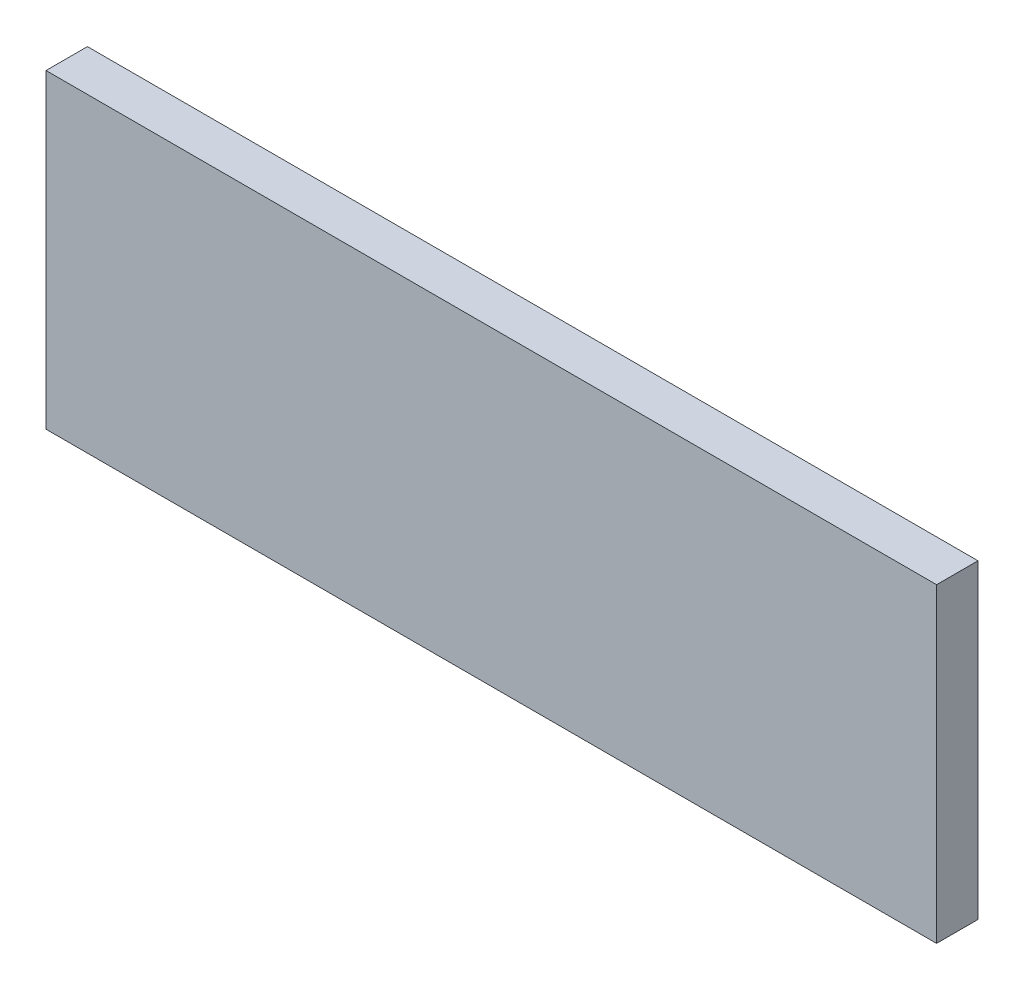
from build123d import *

# Parameters (mm, degrees)
SKETCH1_W           = 109.22
SKETCH1_H           = 38.1
BOSS_EXTRUDE1_DEPTH = 5.08


with BuildPart() as part:
    # Sketch1 → Boss-Extrude1 (new body)
    with BuildSketch(Plane.XY):
        with Locations((54.61, 19.05)):
            Rectangle(SKETCH1_W, SKETCH1_H)
    extrude(amount=BOSS_EXTRUDE1_DEPTH)


solid = part.part
